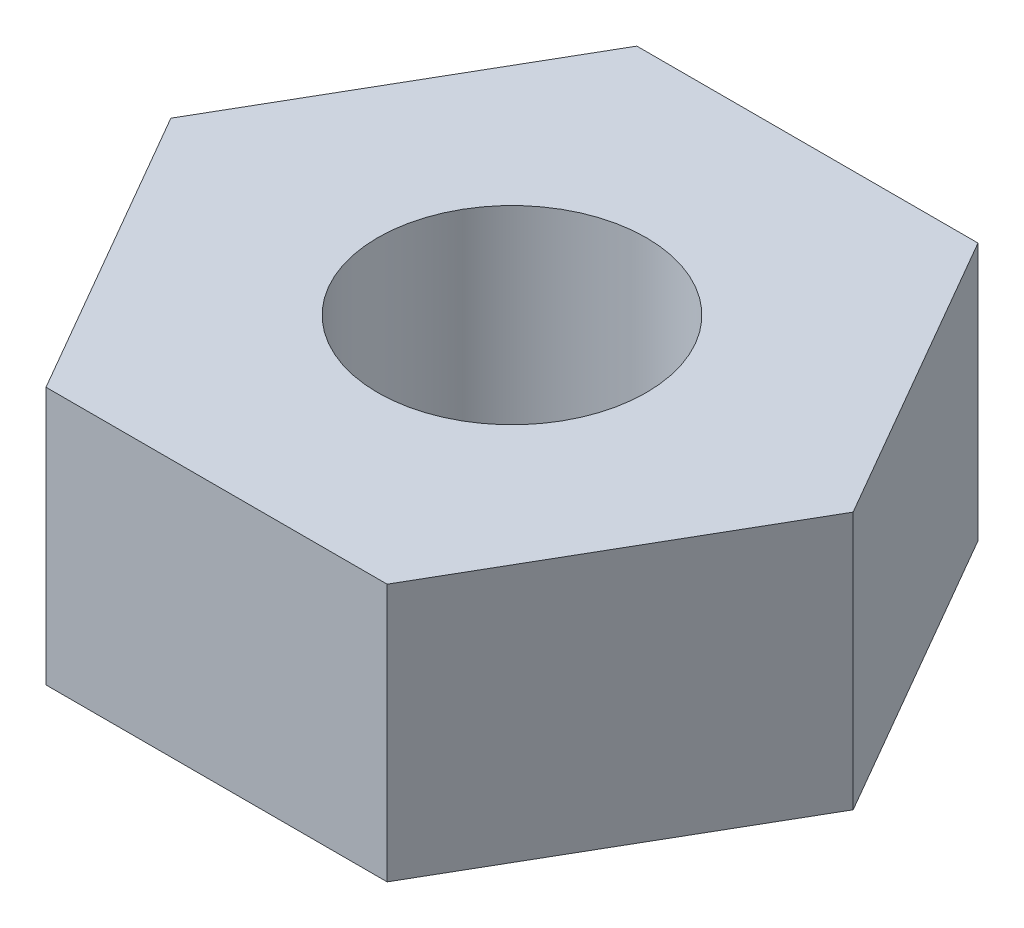
from build123d import *

# Parameters (mm, degrees)
CROQUIS1_R              = 1.25
SALIENTE_EXTRUIR1_DEPTH = 2.4


with BuildPart() as part:
    # Croquis1 → Saliente-Extruir1 (new body)
    with BuildSketch(Plane(origin=(0, 0, 0), x_dir=(1, 0, 0), z_dir=(0, 1, 0))):
        Polygon((-1.58771324, 2.75), (-3.175426481, 0), (-1.58771324, -2.75), (1.58771324, -2.75), (3.175426481, 0), (1.58771324, 2.75), align=None)
        Circle(CROQUIS1_R, mode=Mode.SUBTRACT)
    extrude(amount=SALIENTE_EXTRUIR1_DEPTH)


solid = part.part
